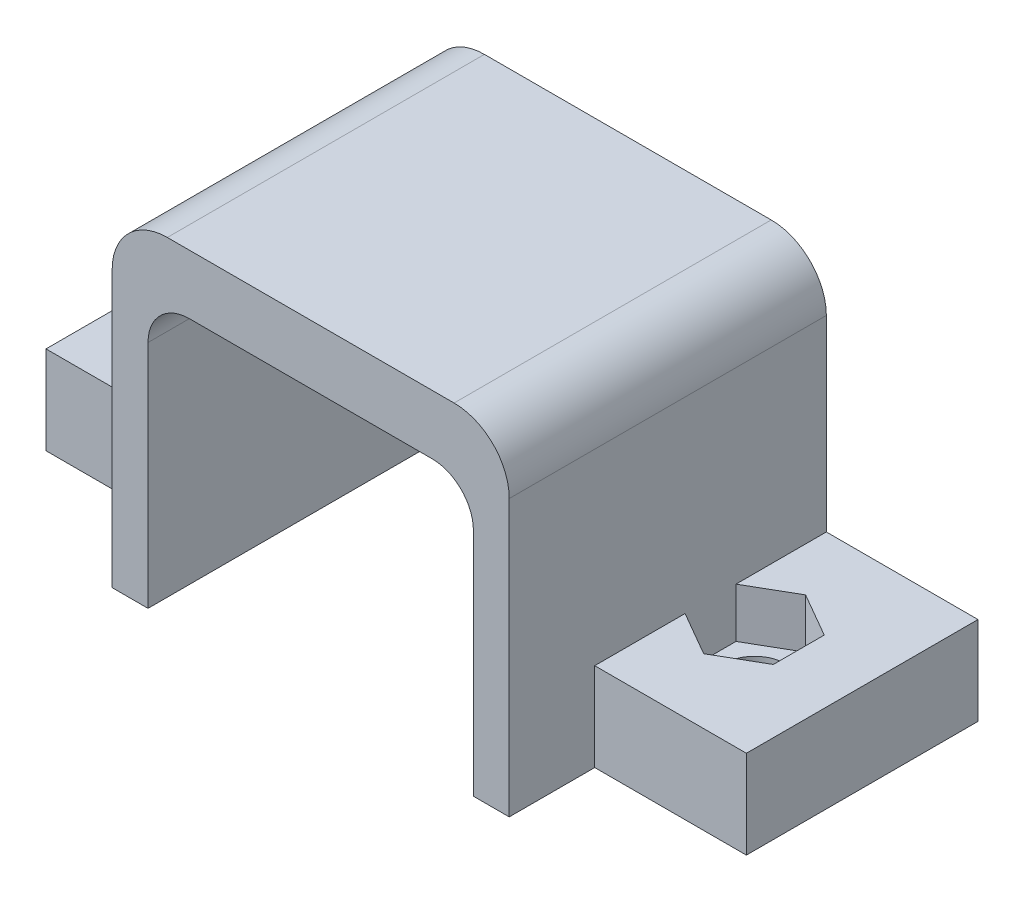
from build123d import *

# Parameters (mm, degrees)
EXTRUDE_1_DEPTH     = 11.5
SKETCH_2_W          = 5.5
SKETCH_2_H          = 8.4
EXTRUDE_2_DEPTH     = 3.2
SKETCH_3_R          = 1.125
CUT_EXTRUDE_1_DEPTH = 4.2
CUT_EXTRUDE_2_DEPTH = 1.8
FILLET_2_R          = 2
FILLET_3_R          = 1.5


with BuildPart() as part:
    # 草图1 → 凸台-拉伸1 (new body)
    with BuildSketch(Plane.XY):
        Polygon((13.1, 0), (14.4, 0), (14.4, 12), (0, 12), (0, 0), (1.3, 0), (1.3, 9.85), (13.1, 9.85), align=None)
    extrude(amount=EXTRUDE_1_DEPTH)

    # 草图2 → 凸台-拉伸2 (add)
    with BuildSketch(Plane.XZ):
        with Locations((-2.75, 4.2)):
            Rectangle(SKETCH_2_W, SKETCH_2_H)
        with Locations((17.15, 4.2)):
            Rectangle(SKETCH_2_W, SKETCH_2_H)
    extrude(amount=-EXTRUDE_2_DEPTH)

    # 草图3 → 切除-拉伸1 (cut, through all)
    with BuildSketch(Plane(origin=(0, 3.2, 0), x_dir=(1, 0, 0), z_dir=(0, 1, 0))):
        with Locations((-1.6, -4.2)):
            Circle(SKETCH_3_R)
        with Locations((16, -4.2)):
            Circle(SKETCH_3_R)
    extrude(amount=-CUT_EXTRUDE_1_DEPTH, mode=Mode.SUBTRACT)

    # 草图4 → 切除-拉伸2 (cut)
    with BuildSketch(Plane(origin=(0, 3.2, 0), x_dir=(1, 0, 0), z_dir=(0, 1, 0))):
        Polygon((-1.6, -2.352479139), (-3.2, -3.276239569), (-3.2, -5.123760431), (-1.6, -6.047520861), (0, -5.123760431), (0, -3.276239569), align=None)
        Polygon((16, -2.352479139), (14.4, -3.276239569), (14.4, -5.123760431), (16, -6.047520861), (17.6, -5.123760431), (17.6, -3.276239569), align=None)
    extrude(amount=-CUT_EXTRUDE_2_DEPTH, mode=Mode.SUBTRACT)

    # 圆角2
    fillet_2_edges = [part.edges().sort_by_distance(p)[0] for p in [
        (0, 12, 5.75),
        (14.4, 12, 5.75),
    ]]
    fillet(fillet_2_edges, radius=FILLET_2_R)

    # 圆角3
    fillet_3_edges = [part.edges().sort_by_distance(p)[0] for p in [
        (13.1, 9.85, 5.75),
        (1.3, 9.85, 5.75),
    ]]
    fillet(fillet_3_edges, radius=FILLET_3_R)


solid = part.part
